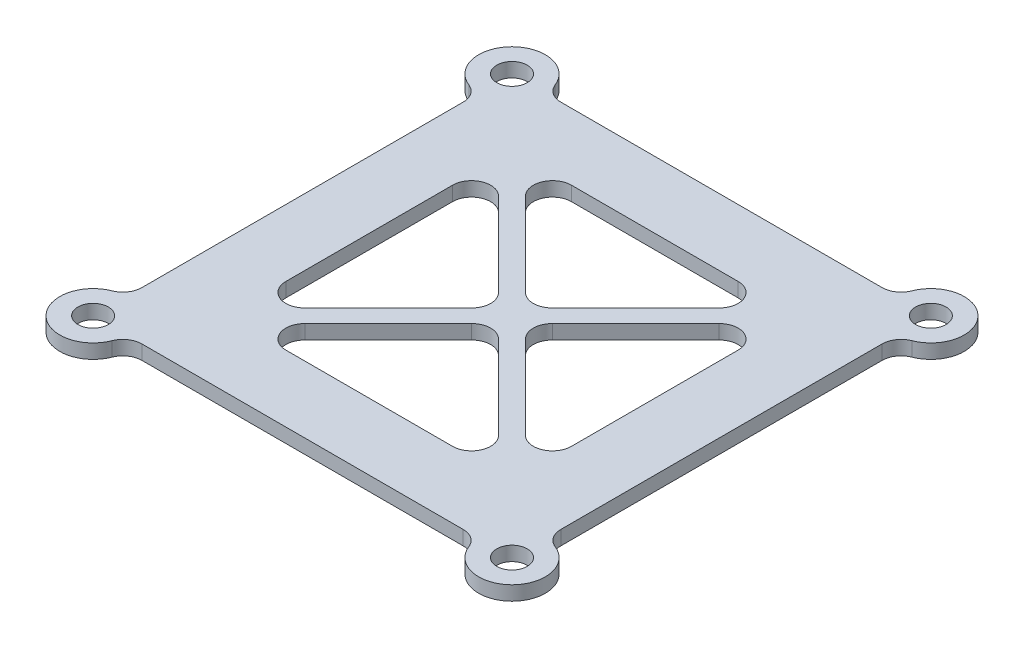
from build123d import *

# Parameters (mm, degrees)
BOSS_EXTRUDE1_DEPTH            = 0.75
FILLET1_R                      = 2
F_3_2_3_2_DIAMETER_HOLE1_D     = 3.2
F_3_2_3_2_DIAMETER_HOLE1_DEPTH = 10
F_3_2_3_2_DIAMETER_HOLE1_TIP   = 0.96137699
CUT_EXTRUDE1_DEPTH             = 1.5
FILLET2_R                      = 2


with BuildPart() as part:
    # Sketch1 → Boss-Extrude1 (new body, symmetric)
    with BuildSketch(Plane(origin=(0, 0, 0), x_dir=(1, 0, 0), z_dir=(0, 1, 0))):
        with BuildLine():
            Line((-18.5, -22), (18.5, -22))
            ThreePointArc((18.5, -22), (24.474873734, -24.474873734), (22, -18.5))
            Line((22, -18.5), (22, 18.5))
            ThreePointArc((22, 18.5), (24.474873734, 24.474873734), (18.5, 22))
            Line((18.5, 22), (-18.5, 22))
            ThreePointArc((-18.5, 22), (-24.474873734, 24.474873734), (-22, 18.5))
            Line((-22, 18.5), (-22, -18.5))
            ThreePointArc((-22, -18.5), (-24.474873734, -24.474873734), (-18.5, -22))
        make_face()
    extrude(amount=BOSS_EXTRUDE1_DEPTH, both=True)

    # Fillet1
    fillet1_edges = [part.edges().sort_by_distance(p)[0] for p in [
        (-18.5, 0, -22),
        (18.5, 0, -22),
        (22, 0, -18.5),
        (22, 0, 18.5),
        (18.5, 0, 22),
        (-18.5, 0, 22),
        (-22, 0, 18.5),
        (-22, 0, -18.5),
    ]]
    fillet(fillet1_edges, radius=FILLET1_R)

    # Ø3.2 (3.2) Diameter Hole1
    with Locations(Plane(origin=(0, 0.75, 0), x_dir=(1, 0, 0), z_dir=(0, 1, 0))):
        with Locations((-22, 22), (-22, -22), (22, -22), (22, 22)):
            Hole(F_3_2_3_2_DIAMETER_HOLE1_D / 2, depth=F_3_2_3_2_DIAMETER_HOLE1_DEPTH)
            with Locations((0, 0, -(F_3_2_3_2_DIAMETER_HOLE1_DEPTH + F_3_2_3_2_DIAMETER_HOLE1_TIP / 2))):  # 118° drill point
                Cone(0, F_3_2_3_2_DIAMETER_HOLE1_D / 2, F_3_2_3_2_DIAMETER_HOLE1_TIP, mode=Mode.SUBTRACT)

    # Sketch4 → Cut-Extrude1 (cut)
    with BuildSketch(Plane(origin=(0, 0.75, 0), x_dir=(1, 0, 0), z_dir=(0, 1, 0))):
        Polygon((-1.414213562, 0), (-15, 13.585786438), (-15, -13.585786438), align=None)
        Polygon((13.585786438, 15), (-13.585786438, 15), (0, 1.414213562), align=None)
        Polygon((15, -13.585786438), (15, 13.585786438), (1.414213562, 0), align=None)
        Polygon((0, -1.414213562), (-13.585786438, -15), (13.585786438, -15), align=None)
    extrude(amount=-CUT_EXTRUDE1_DEPTH, mode=Mode.SUBTRACT)

    # Fillet2
    fillet2_edges = [part.edges().sort_by_distance(p)[0] for p in [
        (-1.414213562, 0, 0),
        (-15, 0, 13.585786438),
        (-15, 0, -13.585786438),
        (13.585786438, 0, -15),
        (0, 0, -1.414213562),
        (-13.585786438, 0, -15),
        (15, 0, -13.585786438),
        (15, 0, 13.585786438),
        (1.414213562, 0, 0),
        (0, 0, 1.414213562),
        (13.585786438, 0, 15),
        (-13.585786438, 0, 15),
    ]]
    fillet(fillet2_edges, radius=FILLET2_R)


solid = part.part
